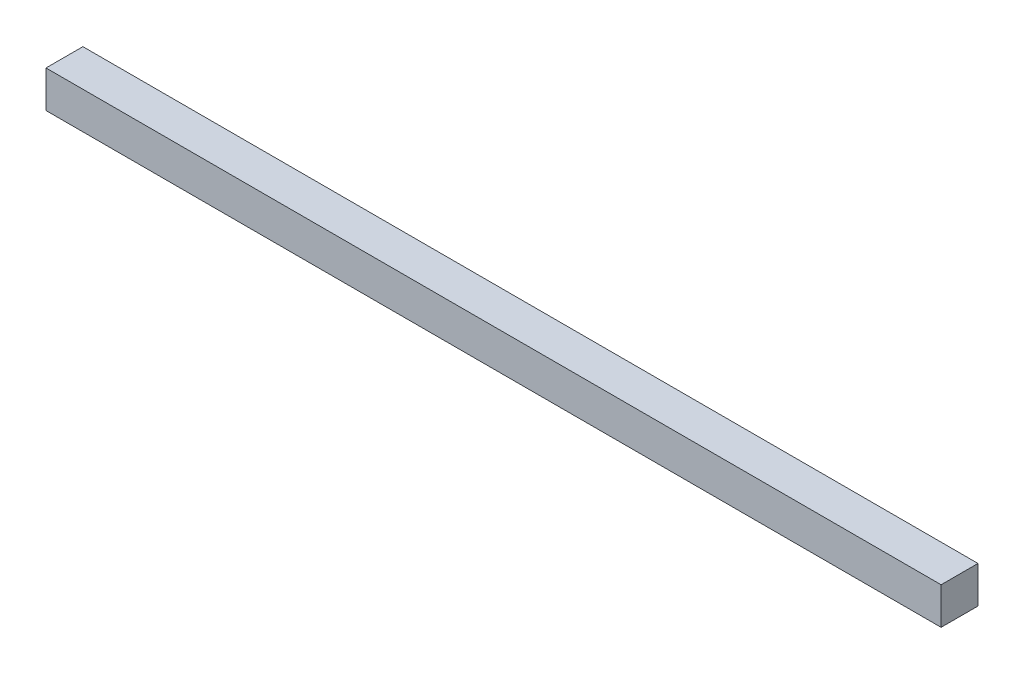
from build123d import *

# Parameters (mm, degrees)
SKETCH1_W           = 462.14
SKETCH1_H           = 19.05
BOSS_EXTRUDE1_DEPTH = 19.05


with BuildPart() as part:
    # Sketch1 → Boss-Extrude1 (new body)
    with BuildSketch(Plane(origin=(0, 0, 0), x_dir=(1, 0, 0), z_dir=(0, 1, 0))):
        Rectangle(SKETCH1_W, SKETCH1_H)
    extrude(amount=BOSS_EXTRUDE1_DEPTH)


solid = part.part
